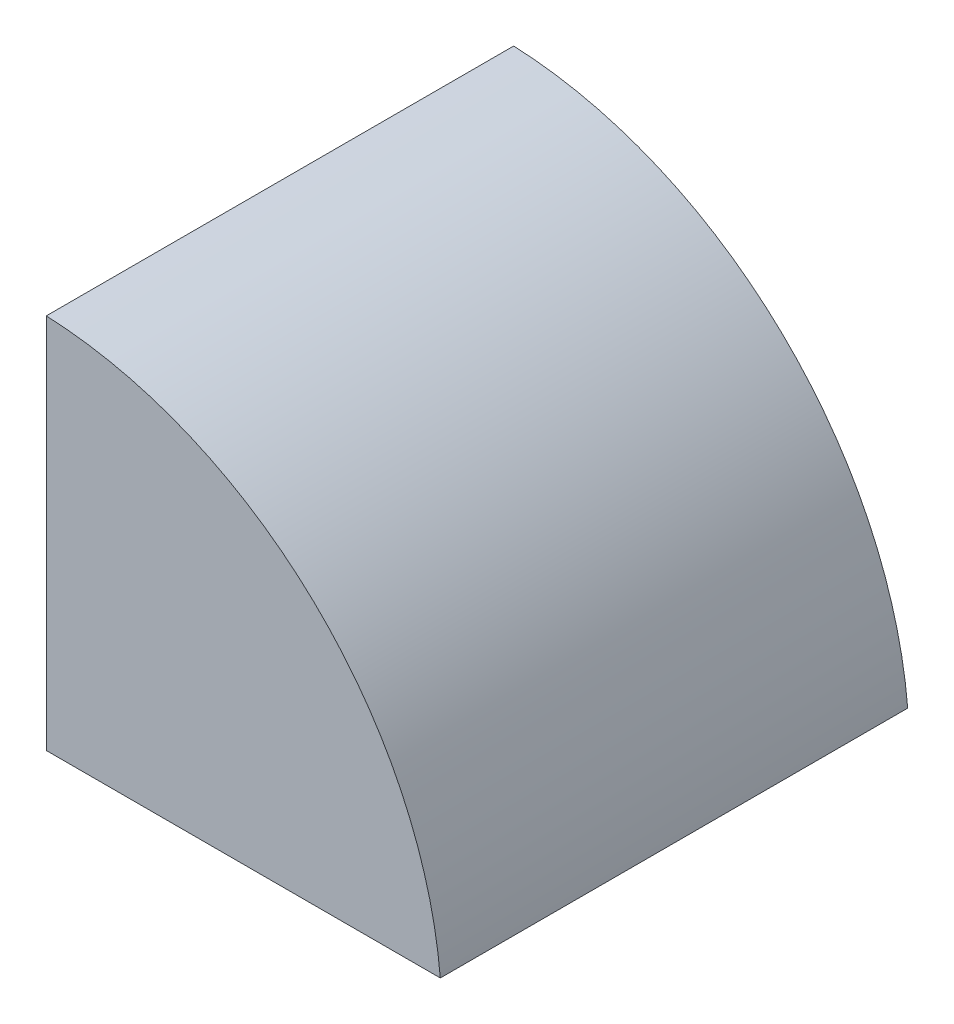
from build123d import *

# Parameters (mm, degrees)
DODANIE_WYCI_GNI_CIE1_DEPTH = 30


with BuildPart() as part:
    # Szkic1 → Dodanie-wyciągnięcie1 (new body)
    with BuildSketch(Plane.XY):
        with BuildLine():
            Line((1.149162211, 2.357632839), (26.439192301, 2.357632839))
            ThreePointArc((26.439192301, 2.357632839), (18.33643465, 19.192823827), (1.149162211, 26.5192147))
            Line((1.149162211, 26.5192147), (1.149162211, 2.357632839))
        make_face()
    extrude(amount=DODANIE_WYCI_GNI_CIE1_DEPTH)


solid = part.part
